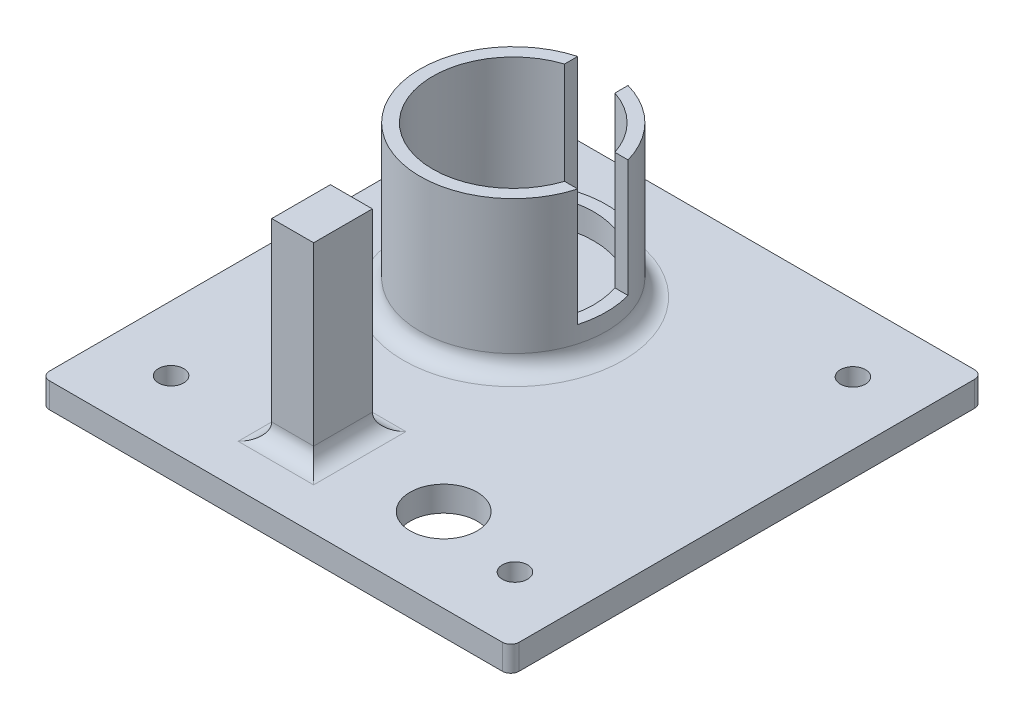
from build123d import *

# Parameters (mm, degrees)
BOSS_EXTRUDE1_DEPTH = 3
SKETCH2_R           = 11.1
BOSS_EXTRUDE2_DEPTH = 18
SKETCH3_R           = 9.6
CUT_EXTRUDE1_DEPTH  = 17
FILLET1_R           = 2
SKETCH4_W           = 10
SKETCH4_H           = 6
SKETCH4_W_2         = 6
SKETCH4_H_2         = 18
CUT_EXTRUDE2_DEPTH  = 14
SKETCH5_R           = 4
CUT_EXTRUDE3_DEPTH  = 4
CUT_EXTRUDE4_REACH  = 5
SKETCH6_R           = 1.5
SKETCH7_W           = 5
SKETCH7_H           = 7
BOSS_EXTRUDE3_DEPTH = 23
FILLET2_R           = 2


with BuildPart() as part:
    # Sketch1 → Boss-Extrude1 (new body)
    with BuildSketch(Plane(origin=(0, 5.44100589, 0), x_dir=(-0.502299233, 0, -0.864693865), z_dir=(0, 1, 0))):
        with BuildLine():
            Line((-182.040025286, -110.769690041), (-135.087148398, -138.044538379))
            ThreePointArc((-135.087148398, -138.044538379), (-134.328597463, -138.146454603), (-133.720155299, -137.682143746))
            Line((-133.720155299, -137.682143746), (-106.595996731, -90.988675017))
            ThreePointArc((-106.595996731, -90.988675017), (-106.494080507, -90.230124082), (-106.958391364, -89.621681919))
            Line((-106.958391364, -89.621681919), (-153.911268252, -62.346833581))
            ThreePointArc((-153.911268252, -62.346833581), (-154.669819187, -62.244917357), (-155.27826135, -62.709228213))
            Line((-155.27826135, -62.709228213), (-182.402419919, -109.402696943))
            ThreePointArc((-182.402419919, -109.402696943), (-182.504336143, -110.161247877), (-182.040025286, -110.769690041))
        make_face()
    extrude(amount=BOSS_EXTRUDE1_DEPTH)

    # Sketch2 → Boss-Extrude2 (add)
    with BuildSketch(Plane(origin=(0, 8.44100589, 0), x_dir=(1, 0, 0), z_dir=(0, 1, 0))):
        with Locations((151.220436476, -66.469362794)):
            Circle(SKETCH2_R)
    extrude(amount=BOSS_EXTRUDE2_DEPTH)

    # Sketch3 → Cut-Extrude1 (cut)
    with BuildSketch(Plane(origin=(0, 26.44100589, 0), x_dir=(1, 0, 0), z_dir=(0, 1, 0))):
        with Locations((151.220436476, -66.469362794)):
            Circle(SKETCH3_R)
    extrude(amount=-CUT_EXTRUDE1_DEPTH, mode=Mode.SUBTRACT)

    # Fillet1
    fillet1_edges = [part.edges().sort_by_distance(p)[0] for p in [
        (140.120436476, 8.44100589, 66.469362794),
    ]]
    fillet(fillet1_edges, radius=FILLET1_R)

    # Sketch4 → Cut-Extrude2 (cut)
    with BuildSketch(Plane(origin=(0, 26.44100589, 0), x_dir=(1, 0, 0), z_dir=(0, 1, 0))):
        with Locations((161.220436476, -66.469362794)):
            Rectangle(SKETCH4_W, SKETCH4_H)
        with Locations((151.220436476, -61.469362794)):
            Rectangle(SKETCH4_W_2, SKETCH4_H_2)
    extrude(amount=-CUT_EXTRUDE2_DEPTH, mode=Mode.SUBTRACT)

    # Sketch5 → Cut-Extrude3 (cut)
    with BuildSketch(Plane(origin=(0, 8.44100589, 0), x_dir=(1, 0, 0), z_dir=(0, 1, 0))):
        with Locations((169.220436476, -92.769362794)):
            Circle(SKETCH5_R)
    extrude(amount=-CUT_EXTRUDE3_DEPTH, mode=Mode.SUBTRACT)

    # Sketch6 → Cut-Extrude4 (cut, up to next)
    with BuildSketch(Plane(origin=(0, 8.44100589, 0), x_dir=(1, 0, 0), z_dir=(0, 1, 0)), mode=Mode.PRIVATE) as cut_extrude4_sk1:
        with Locations((179.720436476, -54.469362794)):
            Circle(SKETCH6_R)
    cut_extrude4_tool1 = extrude(cut_extrude4_sk1.sketch, amount=-CUT_EXTRUDE4_REACH, mode=Mode.PRIVATE) & part.part
    add(cut_extrude4_tool1.solids().sort_by_distance((179.720436, 8.441006, 54.469363))[0], mode=Mode.SUBTRACT)
    # Sketch6 → Cut-Extrude4 (cut, up to next)
    with BuildSketch(Plane(origin=(0, 8.44100589, 0), x_dir=(1, 0, 0), z_dir=(0, 1, 0)), mode=Mode.PRIVATE) as cut_extrude4_sk2:
        with Locations((179.720436476, -94.769362794)):
            Circle(SKETCH6_R)
    cut_extrude4_tool2 = extrude(cut_extrude4_sk2.sketch, amount=-CUT_EXTRUDE4_REACH, mode=Mode.PRIVATE) & part.part
    add(cut_extrude4_tool2.solids().sort_by_distance((179.720436, 8.441006, 94.769363))[0], mode=Mode.SUBTRACT)
    # Sketch6 → Cut-Extrude4 (cut, up to next)
    with BuildSketch(Plane(origin=(0, 8.44100589, 0), x_dir=(1, 0, 0), z_dir=(0, 1, 0)), mode=Mode.PRIVATE) as cut_extrude4_sk3:
        with Locations((138.952841808, -95.003108927)):
            Circle(SKETCH6_R)
    cut_extrude4_tool3 = extrude(cut_extrude4_sk3.sketch, amount=-CUT_EXTRUDE4_REACH, mode=Mode.PRIVATE) & part.part
    add(cut_extrude4_tool3.solids().sort_by_distance((138.952842, 8.441006, 95.003109))[0], mode=Mode.SUBTRACT)

    # Sketch7 → Boss-Extrude3 (add)
    with BuildSketch(Plane(origin=(0, 8.44100589, 0), x_dir=(1, 0, 0), z_dir=(0, 1, 0))):
        with Locations((154.220436476, -92.269362794)):
            Rectangle(SKETCH7_W, SKETCH7_H)
    extrude(amount=BOSS_EXTRUDE3_DEPTH)

    # Fillet2
    fillet2_edges = [part.edges().sort_by_distance(p)[0] for p in [
        (156.720436476, 8.44100589, 92.269362794),
        (154.220436476, 8.44100589, 88.769362794),
        (151.720436476, 8.44100589, 92.269362794),
        (154.220436476, 8.44100589, 95.769362794),
    ]]
    fillet(fillet2_edges, radius=FILLET2_R)


solid = part.part
